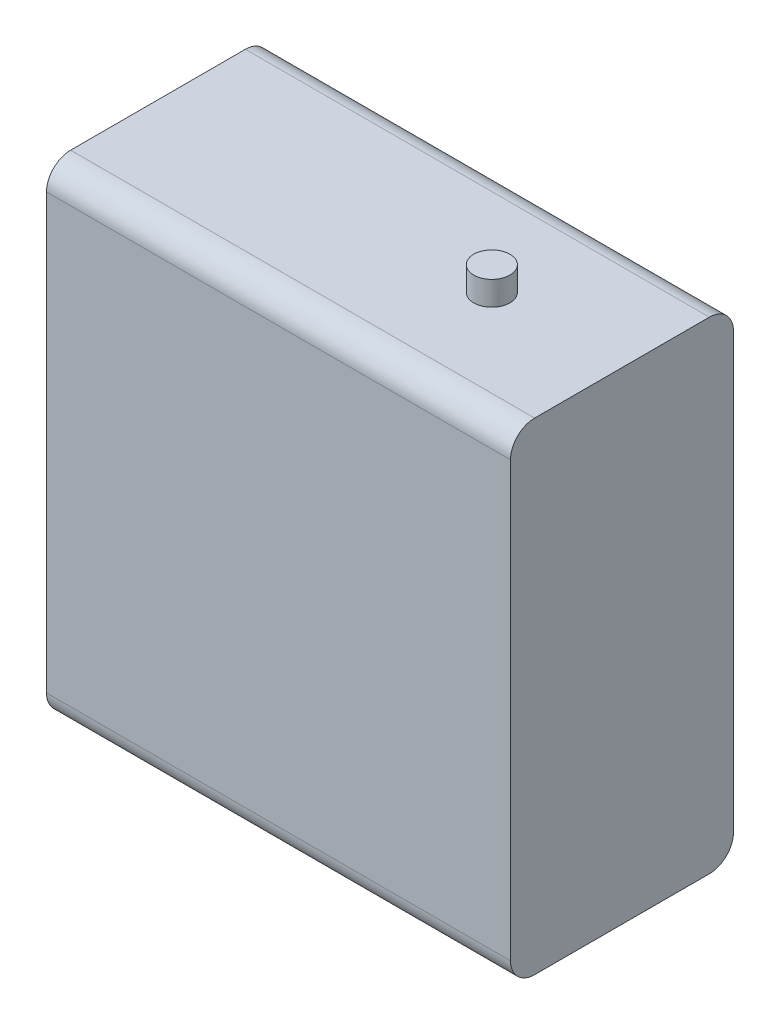
from build123d import *

# Parameters (mm, degrees)
SKETCH2_W           = 38.5
SKETCH2_H           = 40
BOSS_EXTRUDE1_DEPTH = 18.5
FILLET1_R           = 2
SKETCH3_R           = 1.5
BOSS_EXTRUDE2_DEPTH = 2


with BuildPart() as part:
    # Sketch2 → Boss-Extrude1 (new body)
    with BuildSketch(Plane.XY):
        with Locations((19.25, 20)):
            Rectangle(SKETCH2_W, SKETCH2_H)
    extrude(amount=BOSS_EXTRUDE1_DEPTH)

    # Fillet1
    fillet1_edges = [part.edges().sort_by_distance(p)[0] for p in [
        (19.25, 40, 18.5),
        (19.25, 40, 0),
        (19.25, 0, 0),
        (19.25, 0, 18.5),
    ]]
    fillet(fillet1_edges, radius=FILLET1_R)

    # Sketch3 → Boss-Extrude2 (add)
    with BuildSketch(Plane(origin=(0, 40, 0), x_dir=(1, 0, 0), z_dir=(0, 1, 0))):
        with Locations((27.7, -9.25)):
            Circle(SKETCH3_R)
    extrude(amount=BOSS_EXTRUDE2_DEPTH)


solid = part.part
